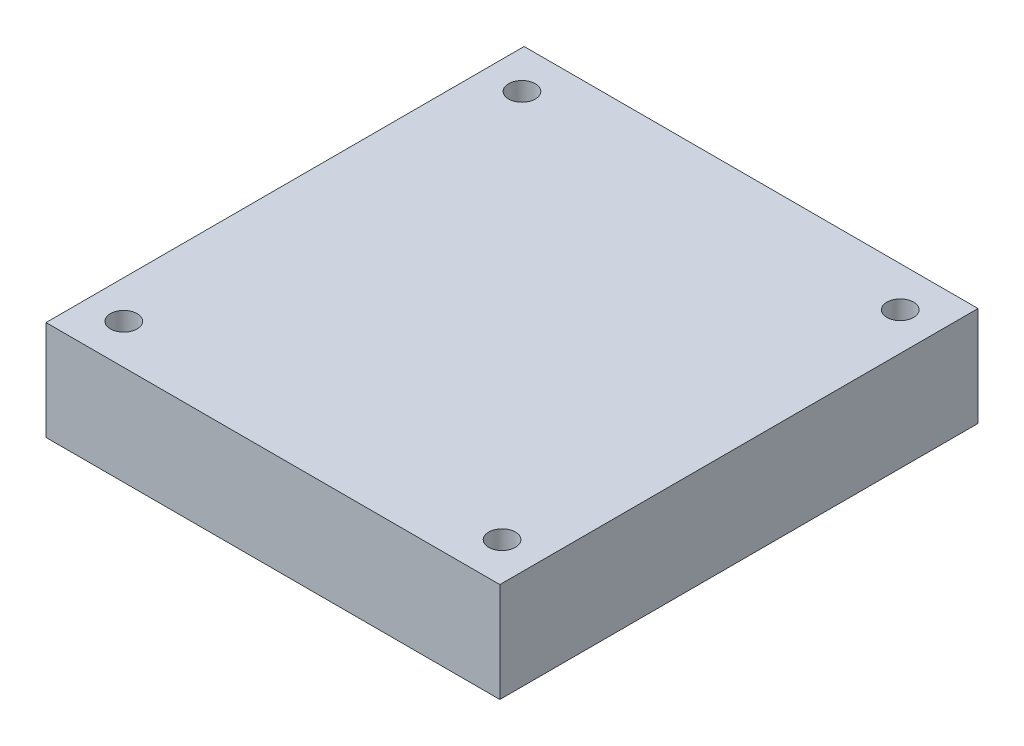
from build123d import *

# Parameters (mm, degrees)
SKETCH1_W                = 57.9
SKETCH1_H                = 61
EXTRUDE1_DEPTH           = 12.7
M3_CLEARANCE_HOLE1_D     = 3.4
M3_CLEARANCE_HOLE1_DEPTH = 12.7
M3_CLEARANCE_HOLE1_TIP   = 1.021463052


with BuildPart() as part:
    # Sketch1 → Extrude1 (new body)
    with BuildSketch(Plane(origin=(0, 0, 0), x_dir=(1, 0, 0), z_dir=(0, 1, 0))):
        Rectangle(SKETCH1_W, SKETCH1_H)
    extrude(amount=EXTRUDE1_DEPTH)

    # M3 Clearance Hole1
    with Locations(Plane(origin=(24.13, 0, -25.4), x_dir=(0, 0, -1), z_dir=(0, -1, 0))):
        with Locations((0, 0), (0, -48.26), (-50.8, -48.26), (-50.8, 0)):
            Hole(M3_CLEARANCE_HOLE1_D / 2, depth=M3_CLEARANCE_HOLE1_DEPTH)
            with Locations((0, 0, -(M3_CLEARANCE_HOLE1_DEPTH + M3_CLEARANCE_HOLE1_TIP / 2))):  # 118° drill point
                Cone(0, M3_CLEARANCE_HOLE1_D / 2, M3_CLEARANCE_HOLE1_TIP, mode=Mode.SUBTRACT)


solid = part.part
